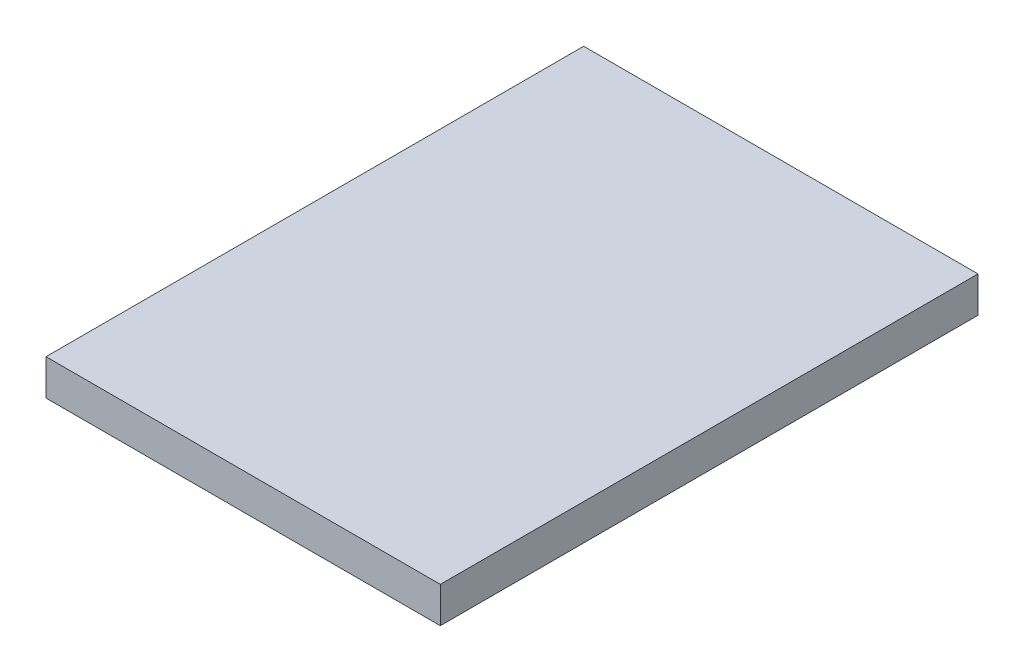
from build123d import *

# Parameters (mm, degrees)
SKETCH1_W           = 220
SKETCH1_H           = 300
BOSS_EXTRUDE1_DEPTH = 20


with BuildPart() as part:
    # Sketch1 → Boss-Extrude1 (new body)
    with BuildSketch(Plane(origin=(0, 0, 0), x_dir=(1, 0, 0), z_dir=(0, 1, 0))):
        Rectangle(SKETCH1_W, SKETCH1_H)
    extrude(amount=BOSS_EXTRUDE1_DEPTH)


solid = part.part
